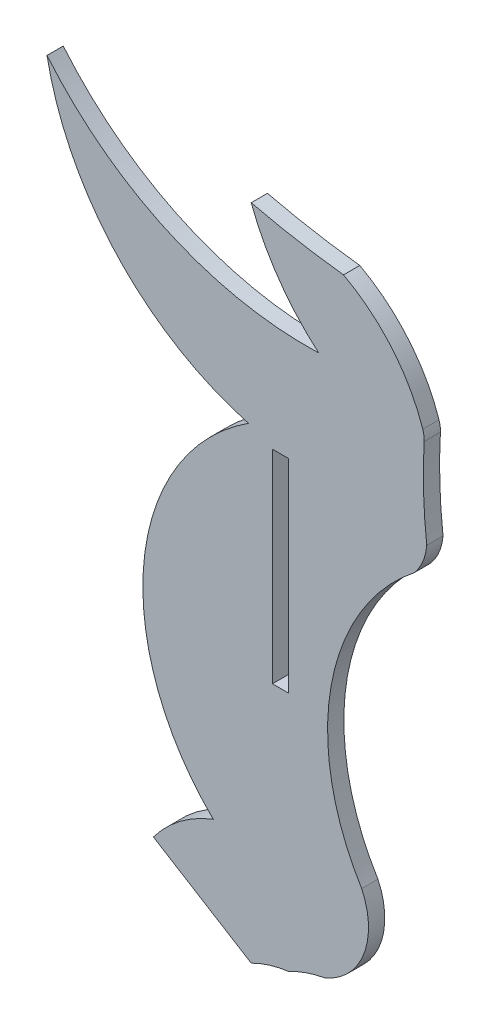
from build123d import *

# Parameters (mm, degrees)
SKETCH1_W           = 1.524
SKETCH1_H           = 19.05
BOSS_EXTRUDE1_DEPTH = 1.524


with BuildPart() as part:
    # Sketch1 → Boss-Extrude1 (new body)
    with BuildSketch(Plane.XY):
        with BuildLine():
            Line((-11.16363506, -211.120891743), (-1.992949981, -216.780601905))
            ThreePointArc((-1.992949981, -216.780601905), (-0.281103266, -216.088759304), (1.524, -215.700600116))
            ThreePointArc((1.524, -215.700600116), (3.171388391, -214.980453866), (4.911266579, -214.527328034))
            ThreePointArc((4.911266579, -214.527328034), (8.56652215, -210.778134694), (8.366250568, -205.545808702))
            ThreePointArc((8.366250568, -205.545808702), (5.494506116, -190.54054727), (13.311403321, -177.414203341))
            ThreePointArc((13.311403321, -177.414203341), (14.109075531, -176.108897248), (14.468404268, -174.621958174))
            ThreePointArc((14.468404268, -174.621958174), (14.169609027, -170.480156419), (14.223154403, -166.327936138))
            ThreePointArc((14.223154403, -166.327936138), (14.204082667, -165.84665661), (14.094500503, -165.377630529))
            ThreePointArc((14.094500503, -165.377630529), (11.21769373, -160.262840376), (6.664633993, -156.56057856))
            ThreePointArc((6.664633993, -156.56057856), (2.313026504, -155.924450691), (-1.992949981, -155.030183999))
            ThreePointArc((-1.992949981, -155.030183999), (0.599102478, -159.944431448), (4.330540862, -164.060853624))
            ThreePointArc((4.330540862, -164.060853624), (-9.729681531, -161.306709082), (-21.139761832, -152.641535487))
            ThreePointArc((-21.139761832, -152.641535487), (-14.612667937, -165.552248896), (-2.254215141, -173.07276217))
            ThreePointArc((-2.254215141, -173.07276217), (-12.048739338, -189.17955679), (-5.548621032, -206.874471292))
            ThreePointArc((-5.548621032, -206.874471292), (-8.65863408, -208.597679765), (-11.16363506, -211.120891743))
        make_face()
        with Locations((0.762, -183.574694423)):
            Rectangle(SKETCH1_W, SKETCH1_H, mode=Mode.SUBTRACT)
    extrude(amount=BOSS_EXTRUDE1_DEPTH)


solid = part.part
